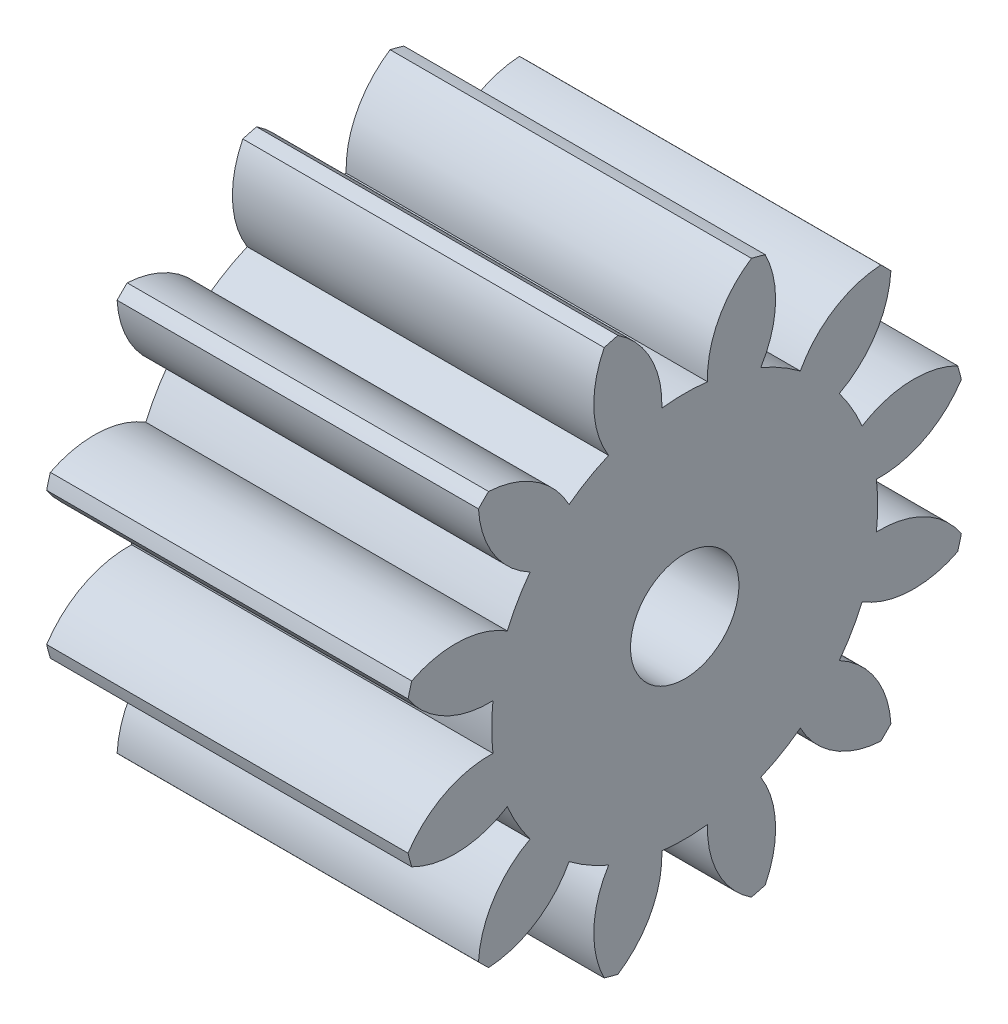
from build123d import *

# Parameters (mm, degrees)
BASPROSKE_W     = 10
BASPROSKE_H     = 7.875
TOOTHCUT_DEPTH  = 15.9676735
TEETHCUTS_COUNT = 12
TEETHCUTS_ANGLE = 330
BORSKE_R        = 1.5
BORE_DEPTH      = 50.0000508


with BuildPart() as part:
    # BasProSke → Base-Revolve (revolve)
    with BuildSketch(Plane(origin=(0, 0, 0), x_dir=(1, 0, 0), z_dir=(0, 1, 0)), mode=Mode.PRIVATE) as base_revolve_sk:
        with Locations((5, 3.9375)):
            Rectangle(BASPROSKE_W, BASPROSKE_H)
    revolve(base_revolve_sk.sketch.rotate(Axis((-10, 0, 0), (1, 0, 0)), 180), axis=Axis((-10, 0, 0), (1, 0, 0)))

    # TooCutSke → ToothCut (cut, through all)
    with BuildSketch(Plane(origin=(0, 0, 0), x_dir=(0, 0, -1), z_dir=(1, 0, 0))):
        with BuildLine():
            ThreePointArc((0.631439839, 5.305305014), (0, 5.34275), (-0.631439839, 5.305305014))
            ThreePointArc((-0.631439839, 5.305305014), (-0.93992237, 6.654932089), (-1.876748184, 7.674251521))
            ThreePointArc((-1.876748184, 7.674251521), (0, 7.9004), (1.876748184, 7.674251521))
            ThreePointArc((1.876748184, 7.674251521), (0.93992237, 6.654932089), (0.631439839, 5.305305014))
        make_face()
    toothcut = extrude(amount=TOOTHCUT_DEPTH, mode=Mode.SUBTRACT)

    # TeethCuts: ToothCut ×12 about axis
    teethcuts_axis = Axis((-10, 0, 0), (1, 0, 0))
    for i in range(1, TEETHCUTS_COUNT):
        add(toothcut.rotate(teethcuts_axis, i * TEETHCUTS_ANGLE / (TEETHCUTS_COUNT - 1)), mode=Mode.SUBTRACT)

    # BorSke → Bore (cut, symmetric)
    with BuildSketch(Plane(origin=(0, 0, 0), x_dir=(0, 0, -1), z_dir=(1, 0, 0))):
        with Locations(Location((0, 0, 0), (0, 0, 180))):
            Circle(BORSKE_R)
    extrude(amount=BORE_DEPTH, both=True, mode=Mode.SUBTRACT)


solid = part.part
